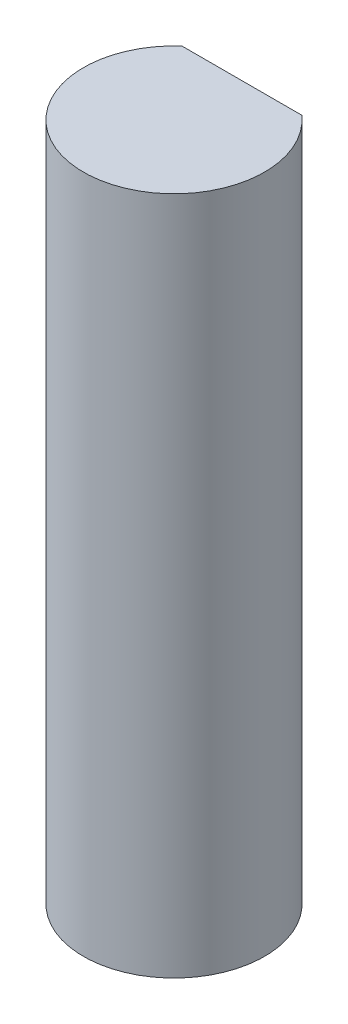
from build123d import *

# Parameters (mm, degrees)
BOSS_EXTRUDE1_DEPTH = 15


with BuildPart() as part:
    # Sketch1 → Boss-Extrude1 (new body)
    with BuildSketch(Plane(origin=(0, 0, 0), x_dir=(1, 0, 0), z_dir=(0, 1, 0))):
        with BuildLine():
            Line((-1.322875656, 1.5), (1.322875656, 1.5))
            ThreePointArc((1.322875656, 1.5), (0, -2), (-1.322875656, 1.5))
        make_face()
    extrude(amount=BOSS_EXTRUDE1_DEPTH)


solid = part.part
